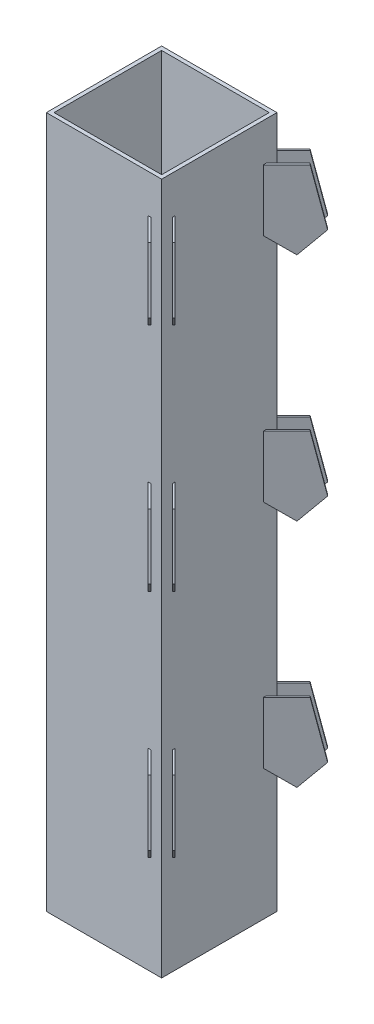
from build123d import *

# Parameters (mm, degrees)
SKETCH1_W             = 3000
SKETCH1_H             = 18000
BOSS_EXTRUDE1_DEPTH   = 3000
BOSS_EXTRUDE2_DEPTH   = 50
BOSS_EXTRUDE3_DEPTH   = 50
BOSS_EXTRUDE3_2_DEPTH = 50
BOSS_EXTRUDE3_3_DEPTH = 50
SKETCH5_W             = 2800
SKETCH5_H             = 2800
CUT_EXTRUDE1_DEPTH    = 18305
BOSS_EXTRUDE4_DEPTH   = 50
BOSS_EXTRUDE5_DEPTH   = 50


with BuildPart() as part:
    # Sketch1 → Boss-Extrude1 (new body)
    with BuildSketch(Plane(origin=(0, 0, 0), x_dir=(0, 0, -1), z_dir=(1, 0, 0))):
        with Locations((-1500, 9000)):
            Rectangle(SKETCH1_W, SKETCH1_H)
    extrude(amount=BOSS_EXTRUDE1_DEPTH)

    # Sketch3 → Boss-Extrude2 (add)
    with BuildSketch(Plane(origin=(1358.578643763, 0, 1358.578643763), x_dir=(0, 1, 0), z_dir=(-0.707106781, 0, -0.707106781))):
        Polygon((17000, 1731.32034356), (17000, 2731.32034356), (15535.241545901, 3054.55813706), (14969.556120952, 2488.87271211), (15500, 1731.32034356), align=None)
        Polygon((11000, 1731.32034356), (11000, 2731.32034356), (9535.241545901, 3054.55813706), (8969.556120952, 2488.87271211), (9500, 1731.32034356), align=None)
        Polygon((5000, 1731.32034356), (5000, 2731.32034356), (3535.241545901, 3054.55813706), (2969.556120952, 2488.87271211), (3500, 1731.32034356), align=None)
    extrude(amount=BOSS_EXTRUDE2_DEPTH)

    # Sketch5 → Cut-Extrude1 (cut)
    with BuildSketch(Plane(origin=(0, 18000, 0), x_dir=(1, 0, 0), z_dir=(0, 1, 0))):
        with Locations((1500, -1500)):
            Rectangle(SKETCH5_W, SKETCH5_H)
    extrude(amount=-CUT_EXTRUDE1_DEPTH, mode=Mode.SUBTRACT)

    # Sketch8 → Boss-Extrude4 (add)
    with BuildSketch(Plane(origin=(-141.421356237, 0, 141.421356237), x_dir=(0, -1, 0), z_dir=(-0.707106781, 0, 0.707106781))):
        Polygon((-3500.000000001, 3852.640687119), (-5000, 3852.640687119), (-5000, 4852.640687119), (-3535.241545901, 5175.878480619), (-2969.557622603, 4610.19305567), align=None)
        Polygon((-9500, 3852.640687119), (-11000, 3852.640687119), (-11000, 4852.640687119), (-9535.241545901, 5175.878480619), (-8969.557622602, 4610.19305567), align=None)
        Polygon((-15500, 3852.640687119), (-17000, 3852.640687119), (-17000, 4852.640687119), (-15535.241545901, 5175.878480619), (-14969.556120952, 4610.19305567), align=None)
    extrude(amount=BOSS_EXTRUDE4_DEPTH)

    # Sketch9 → Boss-Extrude5 (add)
    with BuildSketch(Plane(origin=(141.421356237, 0, -141.421356237), x_dir=(0, -1, 0), z_dir=(-0.707106781, 0, 0.707106781))):
        Polygon((-5000, 3992.640687119), (-3401.971222165, 3992.640687119), (-2969.557622603, 4610.19305567), (-3535.241545901, 5175.878480619), (-5000, 4852.640687119), align=None)
        Polygon((-11000, 3992.640687119), (-9401.971222164, 3992.640687119), (-8969.557622602, 4610.19305567), (-9535.241545901, 5175.878480619), (-11000, 4852.640687119), align=None)
        Polygon((-17000, 3992.640687119), (-15401.970944651, 3992.640687119), (-14969.556120952, 4610.19305567), (-15535.241545901, 5175.878480619), (-17000, 4852.640687119), align=None)
    extrude(amount=-BOSS_EXTRUDE5_DEPTH)


with BuildPart() as body_2:
    # Sketch4 → Boss-Extrude3 (new body)
    with BuildSketch(Plane(origin=(1641.421356237, 0, 1641.421356237), x_dir=(0, 1, 0), z_dir=(-0.707106781, 0, -0.707106781))):
        Polygon((5000, 2731.32034356), (5000, 1871.32034356), (3401.970944651, 1871.32034356), (2969.556120952, 2488.87271211), (3535.241545901, 3054.55813706), align=None)
    extrude(amount=-BOSS_EXTRUDE3_DEPTH)


with BuildPart() as body_3:
    # Sketch4 → Boss-Extrude3 2 (new body)
    with BuildSketch(Plane(origin=(1641.421356237, 0, 1641.421356237), x_dir=(0, 1, 0), z_dir=(-0.707106781, 0, -0.707106781))):
        Polygon((11000, 2731.32034356), (11000, 1871.32034356), (9401.970944651, 1871.32034356), (8969.556120952, 2488.87271211), (9535.241545901, 3054.55813706), align=None)
    extrude(amount=-BOSS_EXTRUDE3_2_DEPTH)


with BuildPart() as body_4:
    # Sketch4 → Boss-Extrude3 3 (new body)
    with BuildSketch(Plane(origin=(1641.421356237, 0, 1641.421356237), x_dir=(0, 1, 0), z_dir=(-0.707106781, 0, -0.707106781))):
        Polygon((17000, 2731.32034356), (17000, 1871.32034356), (15401.970944651, 1871.32034356), (14969.556120952, 2488.87271211), (15535.241545901, 3054.55813706), align=None)
    extrude(amount=-BOSS_EXTRUDE3_3_DEPTH)


solid = Compound([part.part, body_2.part, body_3.part, body_4.part])
